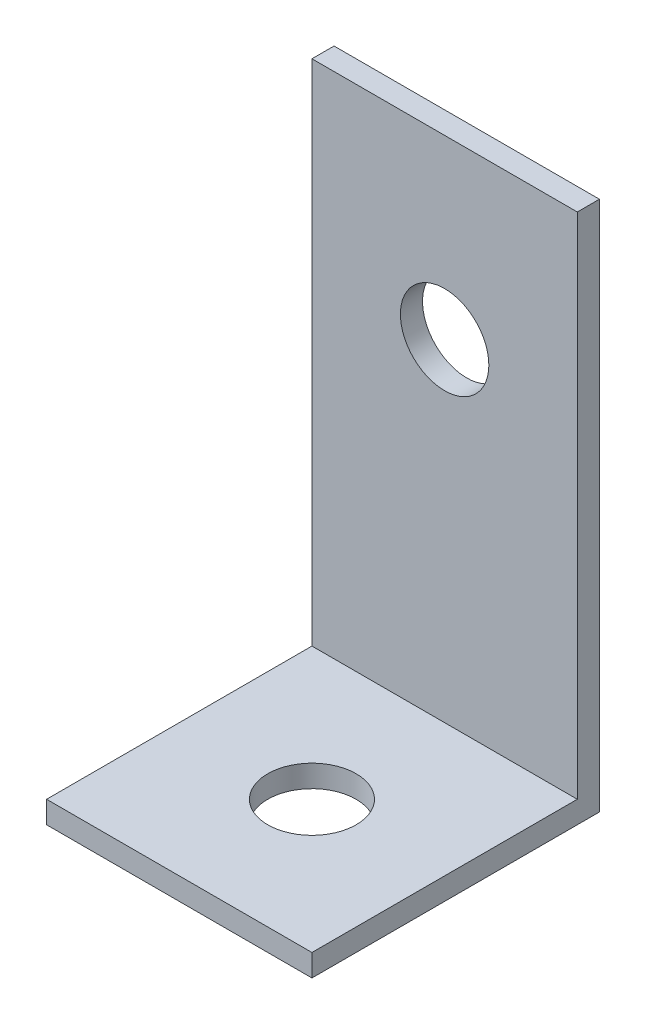
from build123d import *

# Parameters (mm, degrees)
SKETCH1_W           = 19.05
SKETCH1_H           = 38.1
SKETCH1_R           = 3.175
BOSS_EXTRUDE1_DEPTH = 0.79375
SKETCH2_W           = 19.05
SKETCH2_H           = 19.05
SKETCH2_R           = 3.175
BOSS_EXTRUDE2_DEPTH = 1.5875


with BuildPart() as part:
    # Sketch1 → Boss-Extrude1 (new body, symmetric)
    with BuildSketch(Plane.XY):
        Rectangle(SKETCH1_W, SKETCH1_H)
        with Locations((0, 6.35)):
            Circle(SKETCH1_R, mode=Mode.SUBTRACT)
    extrude(amount=BOSS_EXTRUDE1_DEPTH, both=True)

    # Sketch2 → Boss-Extrude2 (add)
    with BuildSketch(Plane.XZ.offset(19.05)):
        with Locations((0, 10.31875)):
            Rectangle(SKETCH2_W, SKETCH2_H)
        with Locations((0, 10.31875)):
            Circle(SKETCH2_R, mode=Mode.SUBTRACT)
    extrude(amount=-BOSS_EXTRUDE2_DEPTH)


solid = part.part
